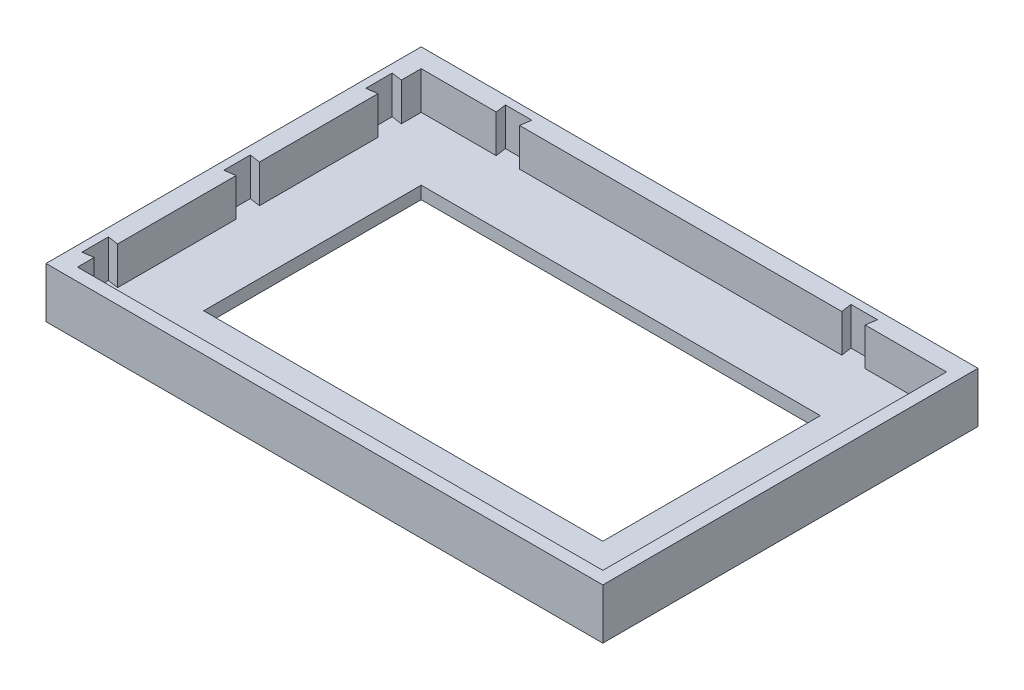
from build123d import *

# Parameters (mm, degrees)
SKETCH1_W           = 88.3
SKETCH1_H           = 59.5
BOSS_EXTRUDE1_DEPTH = 8
SKETCH2_W           = 83.3
SKETCH2_H           = 54.5
CUT_EXTRUDE1_DEPTH  = 6
CUT_EXTRUDE2_DEPTH  = 6
SKETCH4_W           = 63.3
SKETCH4_H           = 34.5
CUT_EXTRUDE3_DEPTH  = 3


with BuildPart() as part:
    # Sketch1 → Boss-Extrude1 (new body)
    with BuildSketch(Plane(origin=(0, 0, 0), x_dir=(1, 0, 0), z_dir=(0, 1, 0))):
        with Locations((5.926671878, -4.296406043)):
            Rectangle(SKETCH1_W, SKETCH1_H)
    extrude(amount=BOSS_EXTRUDE1_DEPTH)

    # Sketch2 → Cut-Extrude1 (cut)
    with BuildSketch(Plane(origin=(0, 8, 0), x_dir=(1, 0, 0), z_dir=(0, 1, 0))):
        with Locations((6.426671878, -4.796406043)):
            Rectangle(SKETCH2_W, SKETCH2_H)
    extrude(amount=-CUT_EXTRUDE1_DEPTH, mode=Mode.SUBTRACT)

    # Sketch3 → Cut-Extrude2 (cut)
    with BuildSketch(Plane(origin=(0, 8, 0), x_dir=(1, 0, 0), z_dir=(0, 1, 0))):
        Polygon((-35.223328122, -29.396406043), (-36.923328122, -29.646406043), (-36.923328122, -25.446406043), (-35.223328122, -25.696406043), align=None)
        Polygon((-35.223328122, -6.896406043), (-36.923328122, -7.146406043), (-36.923328122, -2.946406043), (-35.223328122, -3.196406043), align=None)
        Polygon((-35.223328122, 15.603593957), (-36.923328122, 15.353593957), (-36.923328122, 19.553593957), (-35.223328122, 19.303593957), align=None)
        Polygon((35.176671878, 22.453593957), (31.476671878, 22.453593957), (31.226671878, 24.153593957), (35.426671878, 24.153593957), align=None)
        Polygon((-23.323328122, 22.453593957), (-23.573328122, 24.153593957), (-19.373328122, 24.153593957), (-19.623328122, 22.453593957), align=None)
    extrude(amount=-CUT_EXTRUDE2_DEPTH, mode=Mode.SUBTRACT)

    # Sketch4 → Cut-Extrude3 (cut, through all)
    with BuildSketch(Plane(origin=(0, 2, 0), x_dir=(1, 0, 0), z_dir=(0, 1, 0))):
        with Locations((6.426671878, -4.796406043)):
            Rectangle(SKETCH4_W, SKETCH4_H)
    extrude(amount=-CUT_EXTRUDE3_DEPTH, mode=Mode.SUBTRACT)


solid = part.part
